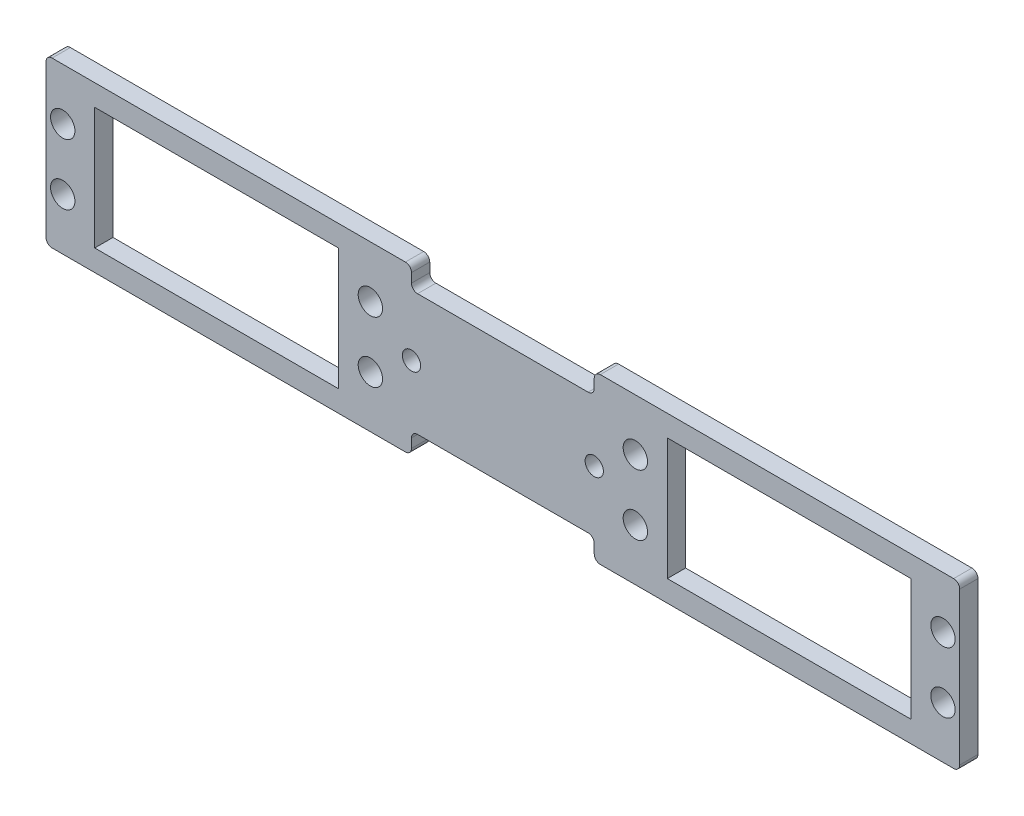
from build123d import *

# Parameters (mm, degrees)
SALIENTE_EXTRUIR1_DEPTH = 3
CROQUIS3_R              = 2
CROQUIS3_W              = 40
CROQUIS3_H              = 20
CORTAR_EXTRUIR1_DEPTH   = 4
REDONDEO1_R             = 1
CROQUIS4_R              = 1.5
CORTAR_EXTRUIR2_DEPTH   = 3


with BuildPart() as part:
    # Croquis1 → Saliente-Extruir1 (new body)
    with BuildSketch(Plane.XY):
        Polygon((75, 13.5), (15, 13.5), (15, 10), (-15, 10), (-15, 13.5), (-75, 13.5), (-75, -13.5), (-15, -13.5), (-15, -10), (15, -10), (15, -13.5), (75, -13.5), align=None)
    extrude(amount=SALIENTE_EXTRUIR1_DEPTH)

    # Croquis3 → Cortar-Extruir1 (cut, through all)
    with BuildSketch(Plane.XY.offset(3)):
        with Locations((-21.75, -5)):
            Circle(CROQUIS3_R)
        with Locations((-21.75, 5)):
            Circle(CROQUIS3_R)
        with Locations((-72.25, -5)):
            Circle(CROQUIS3_R)
        with Locations((-72.25, 5)):
            Circle(CROQUIS3_R)
        with Locations((72.25, 5)):
            Circle(CROQUIS3_R)
        with Locations((72.25, -5)):
            Circle(CROQUIS3_R)
        with Locations((21.75, 5)):
            Circle(CROQUIS3_R)
        with Locations((21.75, -5)):
            Circle(CROQUIS3_R)
        with Locations((-47, 0)):
            Rectangle(CROQUIS3_W, CROQUIS3_H)
        with Locations((47, 0)):
            Rectangle(CROQUIS3_W, CROQUIS3_H)
    extrude(amount=-CORTAR_EXTRUIR1_DEPTH, mode=Mode.SUBTRACT)

    # Redondeo1
    redondeo1_edges = [part.edges().sort_by_distance(p)[0] for p in [
        (-75, -13.5, 1.5),
        (-75, 13.5, 1.5),
        (-15, 13.5, 1.5),
        (-15, 10, 1.5),
        (15, 10, 1.5),
        (15, 13.5, 1.5),
        (75, 13.5, 1.5),
        (75, -13.5, 1.5),
        (15, -13.5, 1.5),
        (15, -10, 1.5),
        (-15, -10, 1.5),
        (-15, -13.5, 1.5),
    ]]
    fillet(redondeo1_edges, radius=REDONDEO1_R)

    # Croquis4 → Cortar-Extruir2 (cut)
    with BuildSketch(Plane.XY.offset(3)):
        with Locations((15, 0)):
            Circle(CROQUIS4_R)
        with Locations((-15, 0)):
            Circle(CROQUIS4_R)
    extrude(amount=-CORTAR_EXTRUIR2_DEPTH, mode=Mode.SUBTRACT)


solid = part.part
